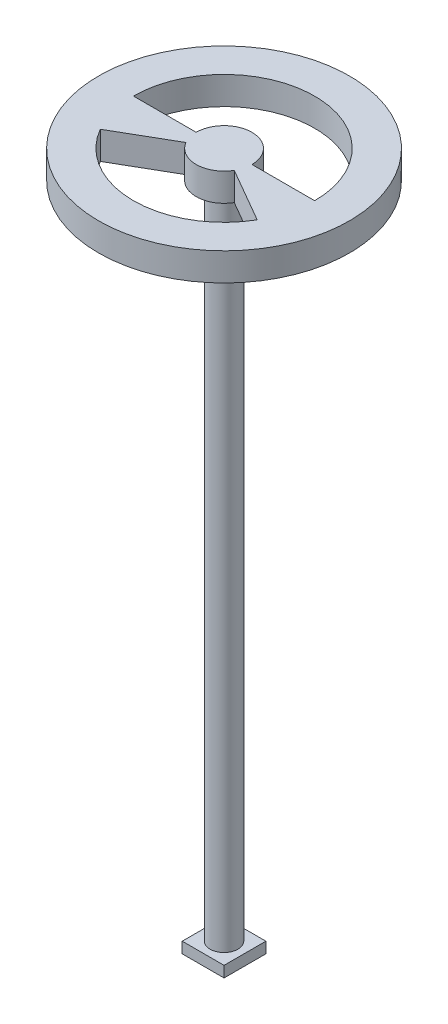
from build123d import *

# Parameters (mm, degrees)
SKETCH1_W           = 38.1
SKETCH1_H           = 38.1
BOSS_EXTRUDE1_DEPTH = 10
SKETCH2_R           = 12.7
BOSS_EXTRUDE2_DEPTH = 600
SKETCH3_R           = 114.3
BOSS_EXTRUDE3_DEPTH = 25.4
CUT_EXTRUDE2_DEPTH  = 25.4


with BuildPart() as part:
    # Sketch1 → Boss-Extrude1 (new body)
    with BuildSketch(Plane(origin=(0, 0, 0), x_dir=(1, 0, 0), z_dir=(0, 1, 0))):
        Rectangle(SKETCH1_W, SKETCH1_H)
    extrude(amount=BOSS_EXTRUDE1_DEPTH)

    # Sketch2 → Boss-Extrude2 (add)
    with BuildSketch(Plane(origin=(0, 10, 0), x_dir=(1, 0, 0), z_dir=(0, 1, 0))):
        Circle(SKETCH2_R)
    extrude(amount=BOSS_EXTRUDE2_DEPTH)

    # Sketch3 → Boss-Extrude3 (add)
    with BuildSketch(Plane(origin=(0, 610, 0), x_dir=(1, 0, 0), z_dir=(0, 1, 0))):
        Circle(SKETCH3_R)
    extrude(amount=BOSS_EXTRUDE3_DEPTH)

    # Sketch5 → Cut-Extrude2 (cut)
    with BuildSketch(Plane(origin=(0, 635.4, 0), x_dir=(1, 0, 0), z_dir=(0, 1, 0))):
        with BuildLine():
            Line((25.4, 0), (82.55, 0))
            ThreePointArc((82.55, 0), (0, 82.55), (-82.55, 0))
            Line((-82.55, 0), (-25.4, 0))
            ThreePointArc((-25.4, 0), (0, 25.4), (25.4, 0))
        make_face()
        with BuildLine():
            Line((71.490397082, -41.275), (21.997045256, -12.7))
            ThreePointArc((21.997045256, -12.7), (0, -25.4), (-21.997045256, -12.7))
            Line((-21.997045256, -12.7), (-71.490397082, -41.275))
            ThreePointArc((-71.490397082, -41.275), (0, -82.55), (71.490397082, -41.275))
        make_face()
    extrude(amount=-CUT_EXTRUDE2_DEPTH, mode=Mode.SUBTRACT)


solid = part.part
